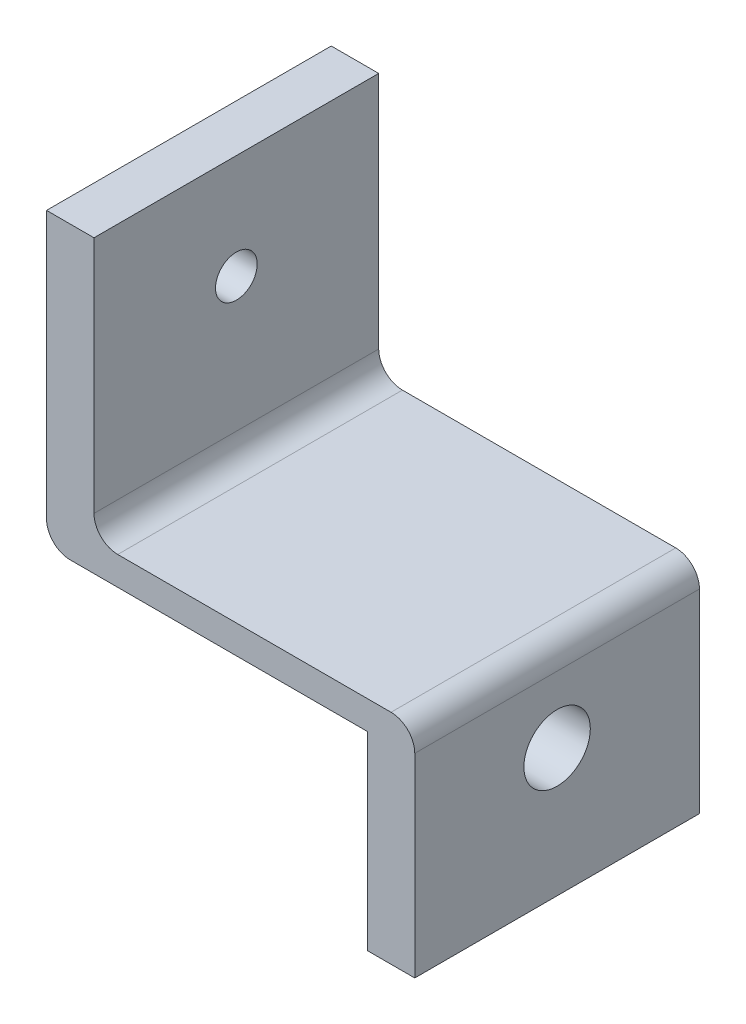
from build123d import *

# Parameters (mm, degrees)
EXTRUDE_THIN1_DEPTH              = 30
F_7_0_7_DIAMETER_HOLE1_D         = 7
TAPPED_HOLE_FOR_8_32_HELICOIL1_D = 4.3942
SKETCH5_W                        = 43.8
SKETCH5_H                        = 32.238868154
EXTRUDE1_DEPTH                   = 31
FILLET1_R                        = 2.5


with BuildPart() as part:
    # Sketch1 → Extrude-Thin1 (new body)
    with BuildSketch(Plane.XY):
        Polygon((0, 30.65), (0, 0), (33.8, 0), (33.8, -20), (38.8, -20), (38.8, 5), (5, 5), (5, 30.65), align=None)
    extrude(amount=-EXTRUDE_THIN1_DEPTH)

    # Ø7.0 (7) Diameter Hole1 (through all)
    with Locations(Plane(origin=(38.8, -6.5, -15), x_dir=(0, 0, 1), z_dir=(1, 0, 0))):
        with Locations((0, 0)):
            Hole(F_7_0_7_DIAMETER_HOLE1_D / 2)

    # Tapped Hole for #8-32 Helicoil1 (through all)
    with Locations(Plane(origin=(5, 19.65, -15), x_dir=(0, 0, 1), z_dir=(1, 0, 0))):
        with Locations((0, 0)):
            Hole(TAPPED_HOLE_FOR_8_32_HELICOIL1_D / 2)

    # Sketch5 → Extrude1 (cut, through all)
    with BuildSketch(Plane.XY):
        with Locations((26.9, 19.119434077)):
            Rectangle(SKETCH5_W, SKETCH5_H)
    extrude(amount=-EXTRUDE1_DEPTH, mode=Mode.SUBTRACT)

    # Fillet1
    fillet1_edges = [part.edges().sort_by_distance(p)[0] for p in [
        (0, 0, -15),
        (38.8, 3, -15),
        (5, 3, -15),
    ]]
    fillet(fillet1_edges, radius=FILLET1_R)


solid = part.part
